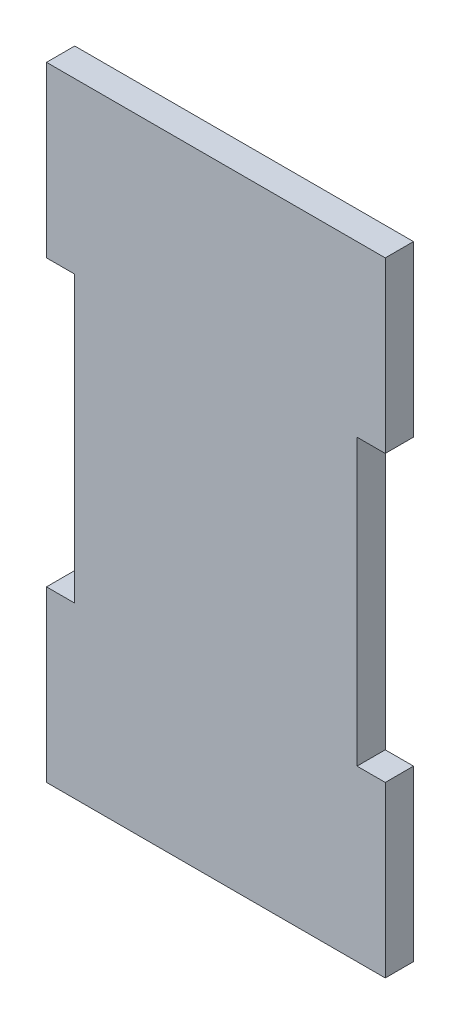
from build123d import *

# Parameters (mm, degrees)
BOSS_EXTRUDE1_DEPTH = 3.175


with BuildPart() as part:
    # Sketch1 → Boss-Extrude1 (new body)
    with BuildSketch(Plane.XY):
        Polygon((-34.925, 315.876009731), (-38.1, 315.876009731), (-38.1, 296.826009731), (-34.925, 296.826009731), (-34.925, 264.785050798), (-38.1, 264.785050798), (-38.1, 245.735050798), (-34.925, 245.735050798), (-3.175, 245.735050798), (0, 245.735050798), (0, 264.785050798), (-3.175, 264.785050798), (-3.175, 296.826009731), (0, 296.826009731), (0, 315.876009731), (-3.175, 315.876009731), align=None)
    extrude(amount=BOSS_EXTRUDE1_DEPTH)


solid = part.part
